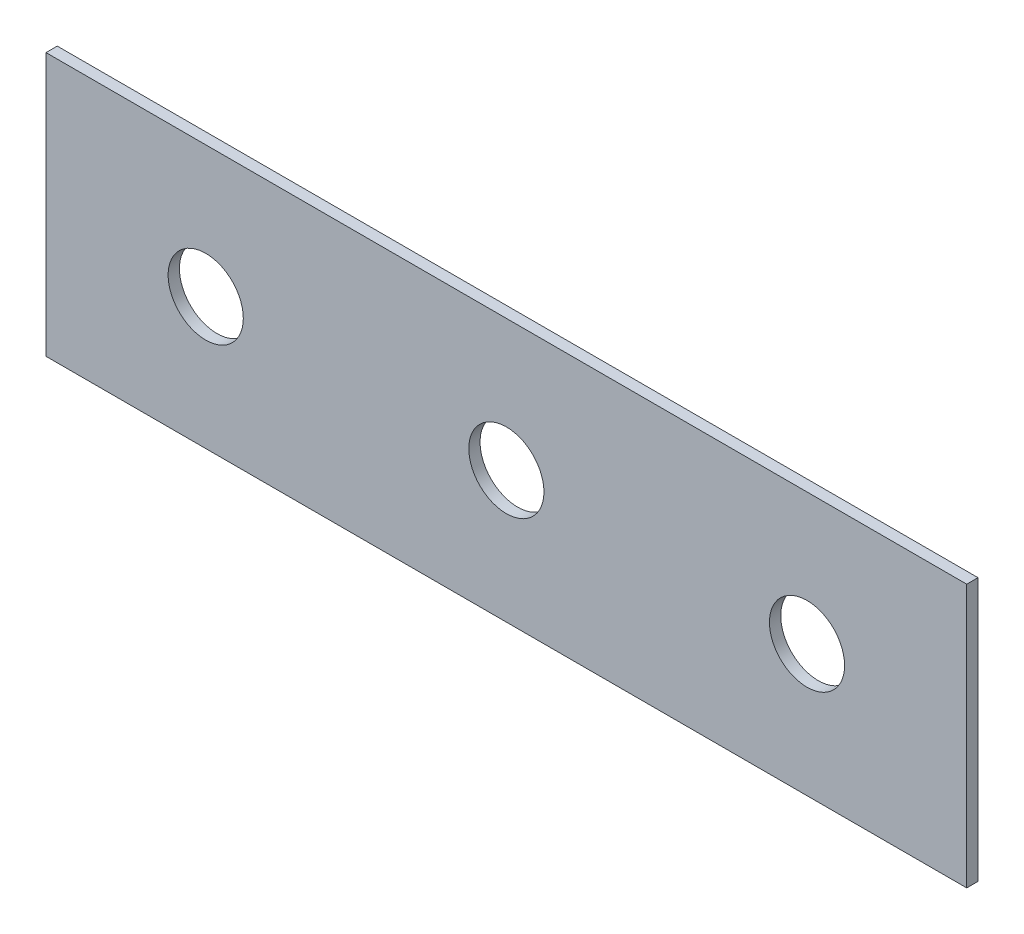
from build123d import *

# Parameters (mm, degrees)
SKETCH1_W           = 245
SKETCH1_H           = 70
BOSS_EXTRUDE1_DEPTH = 3
SKETCH2_R           = 10
CUT_EXTRUDE1_DEPTH  = 3


with BuildPart() as part:
    # Sketch1 → Boss-Extrude1 (new body)
    with BuildSketch(Plane.XY):
        Rectangle(SKETCH1_W, SKETCH1_H)
    extrude(amount=BOSS_EXTRUDE1_DEPTH)

    # Sketch2 → Cut-Extrude1 (cut)
    with BuildSketch(Plane.XY.offset(3)):
        with Locations((-80, 0)):
            Circle(SKETCH2_R)
        Circle(SKETCH2_R)
        with Locations((80, 0)):
            Circle(SKETCH2_R)
    extrude(amount=-CUT_EXTRUDE1_DEPTH, mode=Mode.SUBTRACT)


solid = part.part
